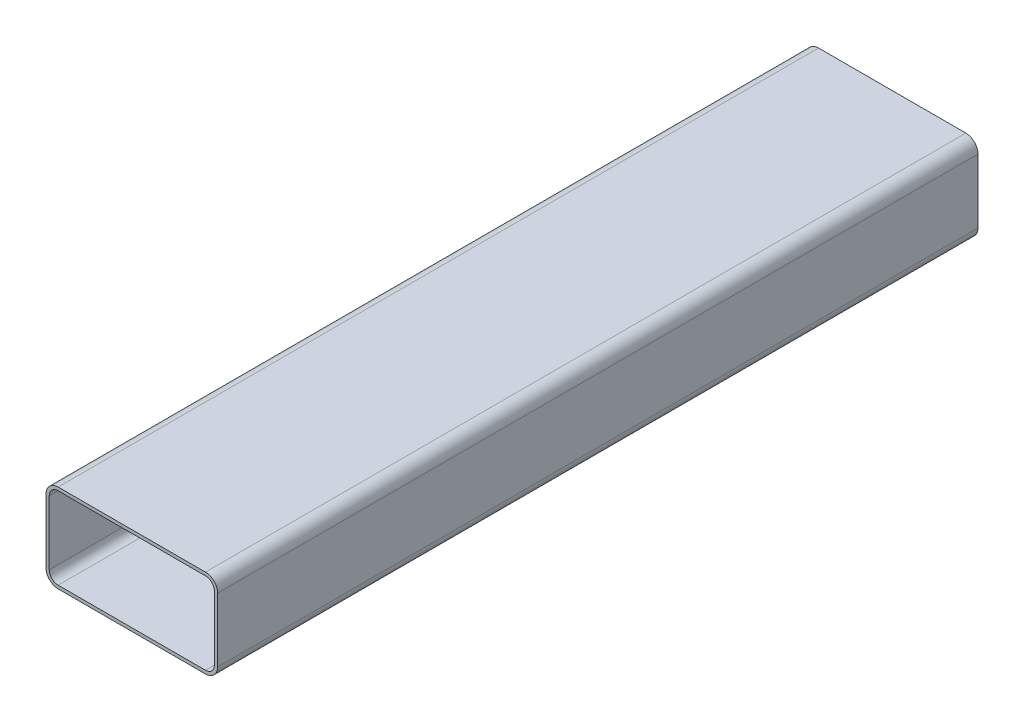
from build123d import *

# Parameters (mm, degrees)
BOSS_EXTRUDE1_DEPTH = 508


with BuildPart() as part:
    # Sketch1 → Boss-Extrude1 (new body)
    with BuildSketch(Plane.XY):
        with BuildLine():
            Line((-49.2151, -29.464), (49.2151, -29.464))
            ThreePointArc((49.2151, -29.464), (54.942664928, -27.091564928), (57.3151, -21.364))
            Line((57.3151, -21.364), (57.3151, 21.364))
            ThreePointArc((57.3151, 21.364), (54.942664928, 27.091564928), (49.2151, 29.464))
            Line((49.2151, 29.464), (-49.2151, 29.464))
            ThreePointArc((-49.2151, 29.464), (-54.942664928, 27.091564928), (-57.3151, 21.364))
            Line((-57.3151, 21.364), (-57.3151, -21.364))
            ThreePointArc((-57.3151, -21.364), (-54.942664928, -27.091564928), (-49.2151, -29.464))
        make_face()
        with BuildLine():
            Line((-49.2161, -27.305), (49.2161, -27.305))
            ThreePointArc((49.2161, -27.305), (53.41631428, -25.56521428), (55.1561, -21.365))
            Line((55.1561, -21.365), (55.1561, 21.365))
            ThreePointArc((55.1561, 21.365), (53.41631428, 25.56521428), (49.2161, 27.305))
            Line((49.2161, 27.305), (-49.2161, 27.305))
            ThreePointArc((-49.2161, 27.305), (-53.41631428, 25.56521428), (-55.1561, 21.365))
            Line((-55.1561, 21.365), (-55.1561, -21.365))
            ThreePointArc((-55.1561, -21.365), (-53.41631428, -25.56521428), (-49.2161, -27.305))
        make_face(mode=Mode.SUBTRACT)
    extrude(amount=BOSS_EXTRUDE1_DEPTH)


solid = part.part
